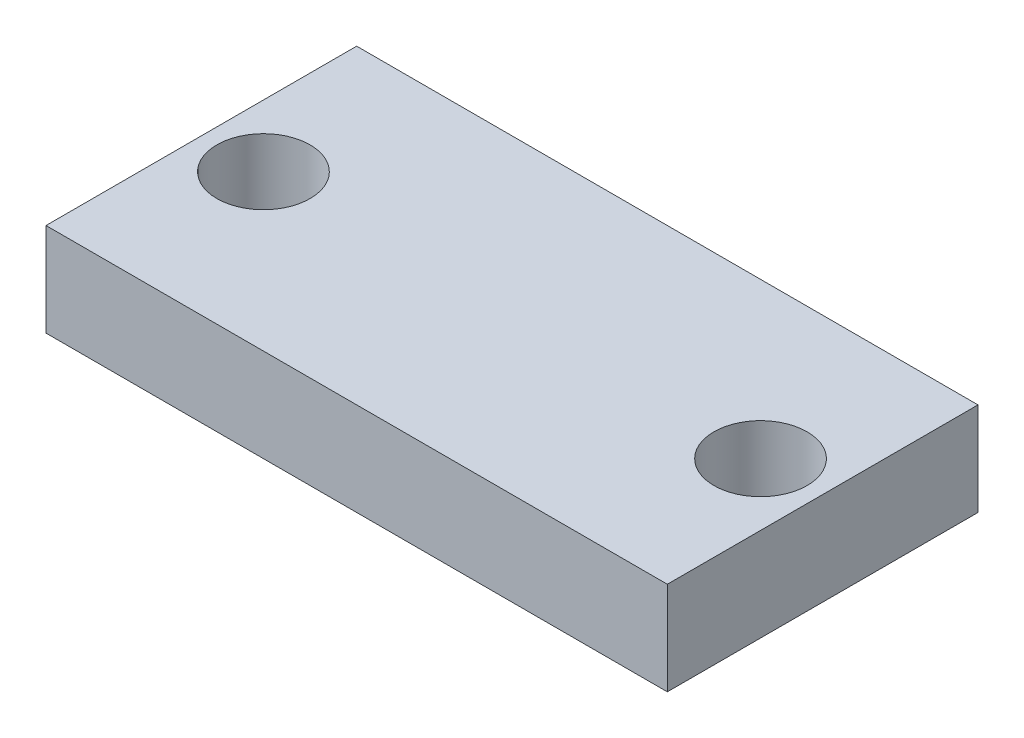
from build123d import *

# Parameters (mm, degrees)
SKETCH_1_R      = 1.5
EXTRUDE_1_DEPTH = 3


with BuildPart() as part:
    # 草图1 → 凸台-拉伸1 (new body)
    with BuildSketch(Plane(origin=(0, 0, 0), x_dir=(1, 0, 0), z_dir=(0, 1, 0))):
        Polygon((0, 0), (0, 5.286885246), (-20, 5.286885246), (-20, -4.713114754), (0, -4.713114754), align=None)
        with Locations((-18, 0.286885246)):
            Circle(SKETCH_1_R, mode=Mode.SUBTRACT)
        with Locations((-2, 0.286885246)):
            Circle(SKETCH_1_R, mode=Mode.SUBTRACT)
    extrude(amount=EXTRUDE_1_DEPTH)


solid = part.part
